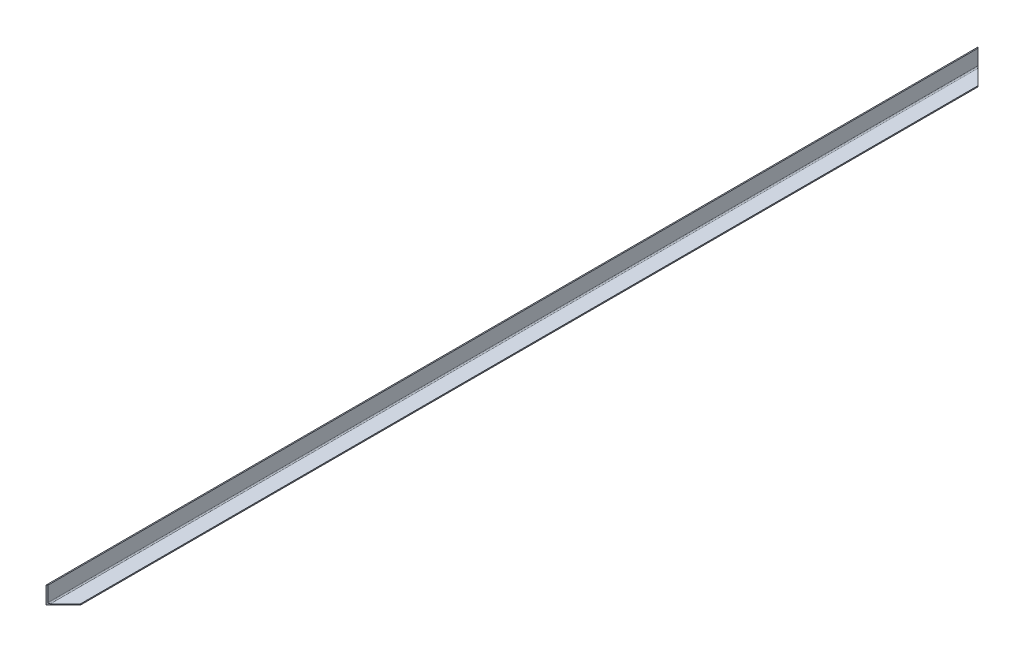
from build123d import *

# Parameters (mm, degrees)
BOSS_EXTRUDE1_DEPTH      = 1368.425
BOSS_EXTRUDE1_DEPTH_BACK = 1368.425
CUT_EXTRUDE1_DEPTH       = 48.625
CUT_EXTRUDE1_DEPTH_BACK  = 4.175


with BuildPart() as part:
    # Sketch4 → Boss-Extrude1 (new body, two sides)
    with BuildSketch(Plane.XY) as boss_extrude1_sk:
        with BuildLine():
            Line((-22.225, -18.838333333), (-22.225, 25.4))
            Line((-22.225, 25.4), (-25.4, 25.4))
            Line((-25.4, 25.4), (-25.4, -25.4))
            Line((-25.4, -25.4), (25.4, -25.4))
            Line((25.4, -25.4), (25.4, -22.225))
            Line((25.4, -22.225), (-18.838333333, -22.225))
            ThreePointArc((-18.838333333, -22.225), (-21.233068299, -21.233068299), (-22.225, -18.838333333))
        make_face()
    extrude(amount=BOSS_EXTRUDE1_DEPTH)
    extrude(boss_extrude1_sk.sketch, amount=-BOSS_EXTRUDE1_DEPTH_BACK)

    # Sketch5 → Cut-Extrude1 (cut, two sides)
    with BuildSketch(Plane(origin=(0, -22.225, 0), x_dir=(1, 0, 0), z_dir=(0, 1, 0))) as cut_extrude1_sk:
        Polygon((-25.4, 1368.425), (25.4, 1317.625), (25.4, 1368.425), align=None)
        Polygon((25.4, -1368.425), (-25.4, -1368.425), (25.4, -1317.625), align=None)
    extrude(amount=CUT_EXTRUDE1_DEPTH, mode=Mode.SUBTRACT)
    extrude(cut_extrude1_sk.sketch, amount=-CUT_EXTRUDE1_DEPTH_BACK, mode=Mode.SUBTRACT)


solid = part.part
